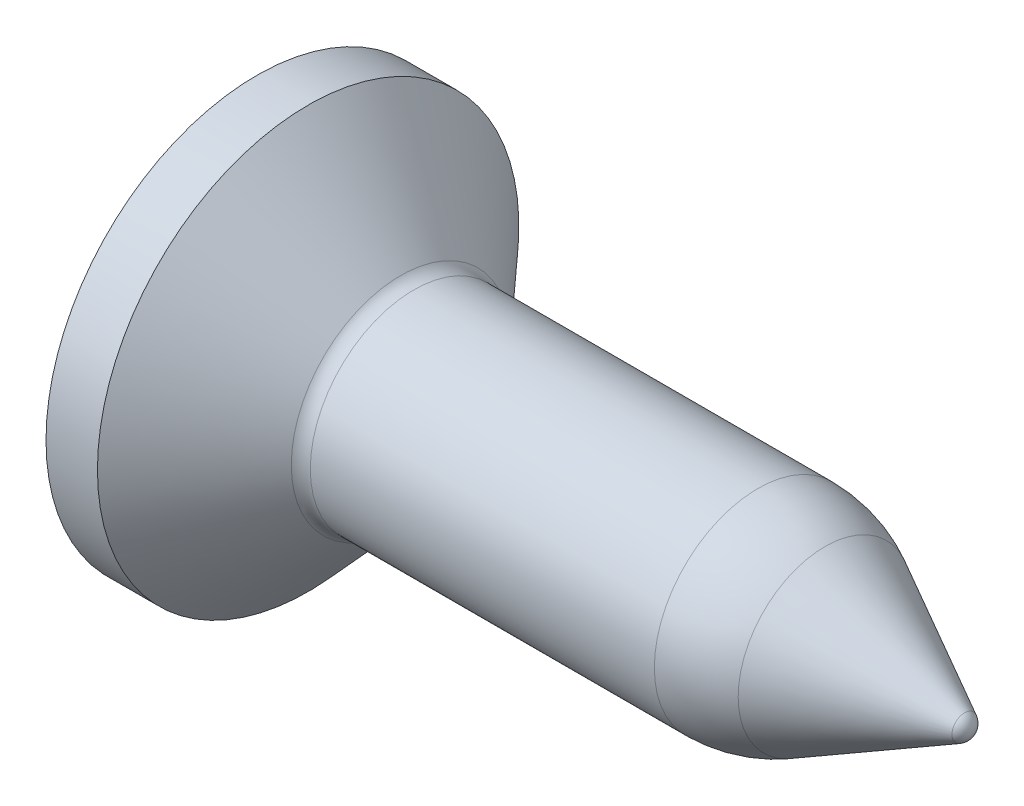
from build123d import *

# Parameters (mm, degrees)
CUT_EXTRUDE1_DEPTH = 0.5


with BuildPart() as part:
    # Sketch1 → Revolve1 (revolve)
    with BuildSketch(Plane.XY):
        with BuildLine():
            Line((0, 0), (0, 2.95))
            Line((0, 2.95), (0.72, 2.95))
            Line((0.72, 2.95), (2.015389317, 1.531420951))
            ThreePointArc((2.015389317, 1.531420951), (2.099115814, 1.47125914), (2.2, 1.45))
            Line((2.2, 1.45), (7.016541593, 1.45))
            ThreePointArc((7.016541593, 1.45), (7.500560514, 1.390547779), (7.955803436, 1.215725683))
            Line((7.955803436, 1.215725683), (9.909315501, 0.176572568))
            ThreePointArc((9.909315501, 0.176572568), (9.986832072, 0.102992143), (10.015389317, 0))
            Line((10.015389317, 0), (0, 0))
        make_face()
    revolve(axis=Axis((-3.974685283, 0, 0), (1, 0, 0)))

    # Sketch2 → Cut-Extrude1 (cut)
    with BuildSketch(Plane.ZY):
        Polygon((-0.25, 1.5), (0.25, 1.5), (0.437370289, 0.437370289), (1.5, 0.25), (1.5, -0.25), (0.437370289, -0.437370289), (0.25, -1.5), (-0.25, -1.5), (-0.437370289, -0.437370289), (-1.5, -0.25), (-1.5, 0.25), (-0.437370289, 0.437370289), align=None)
    extrude(amount=-CUT_EXTRUDE1_DEPTH, mode=Mode.SUBTRACT)


solid = part.part
